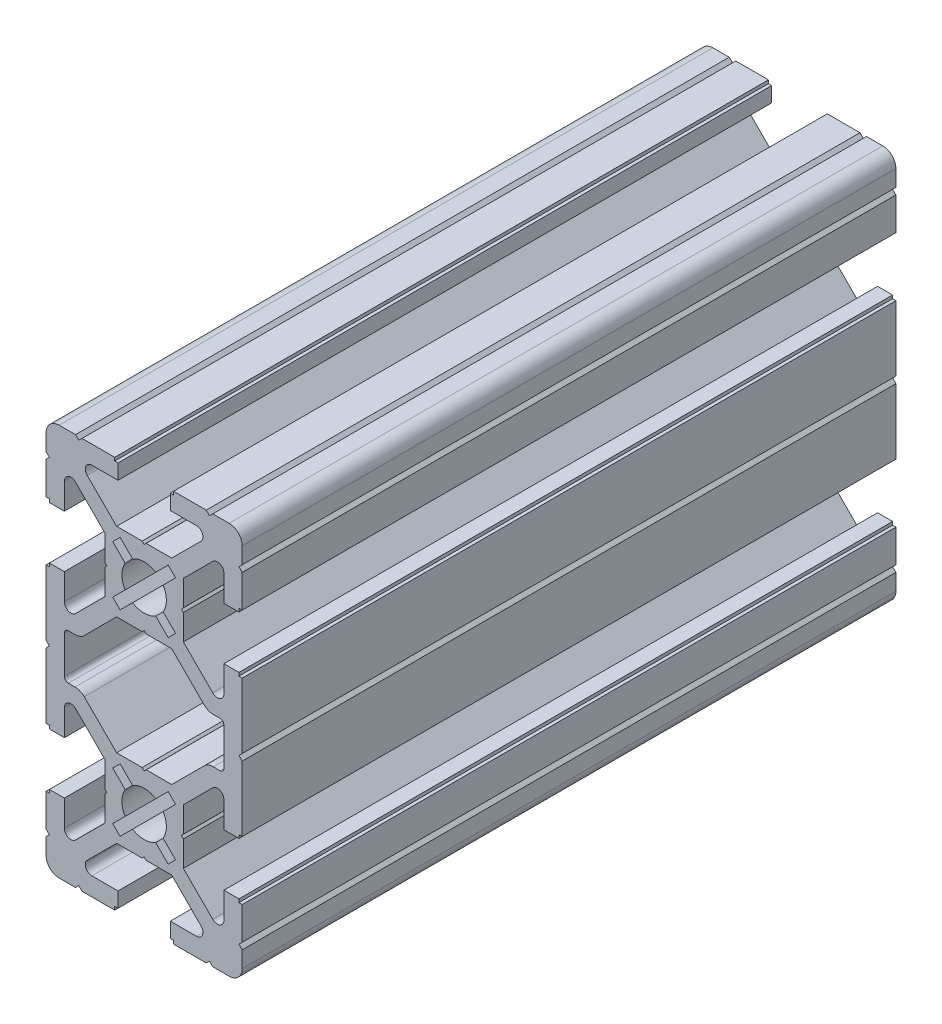
from build123d import *

# Parameters (mm, degrees)
Y_KSEKLIK_EKSTR_ZYON1_DEPTH = 100


with BuildPart() as part:
    # Çizim1 → Yükseklik-Ekstrüzyon1 (new body)
    with BuildSketch(Plane.XY.offset(100)):
        with BuildLine():
            Line((-4.214213564, 21), (-8.70710678, 25.492893215))
            ThreePointArc((-8.70710678, 25.492893215), (-8.923879532, 26.582683434), (-7.999999995, 27.200000005))
            Line((-7.999999995, 27.200000005), (-4.000000001, 27.200000005))
            Line((-4.000000001, 27.200000005), (-4.000000001, 29.500000001))
            Line((-4.000000001, 29.500000001), (-4.500000001, 29.500000001))
            Line((-4.500000001, 29.500000001), (-4.500000001, 29.999999999))
            Line((-4.500000001, 29.999999999), (-9.500000003, 29.999999999))
            Line((-9.500000003, 29.999999999), (-10.000000002, 29.499999999))
            Line((-10.000000002, 29.499999999), (-10.500000001, 29.999999999))
            Line((-10.500000001, 29.999999999), (-13, 29.999999999))
            ThreePointArc((-13, 29.999999999), (-14.414213562, 29.414213561), (-15, 27.999999999))
            Line((-15, 27.999999999), (-15, 25.5))
            Line((-15, 25.5), (-14.500000001, 25.000000001))
            Line((-14.500000001, 25.000000001), (-15, 24.500000001))
            Line((-15, 24.500000001), (-15, 19.5))
            Line((-15, 19.5), (-14.5, 19.5))
            Line((-14.5, 19.5), (-14.5, 19))
            Line((-14.5, 19), (-12.200000005, 19))
            Line((-12.200000005, 19), (-12.200000005, 22.999999994))
            ThreePointArc((-12.200000005, 22.999999994), (-11.582683434, 23.923879532), (-10.492893215, 23.707106779))
            Line((-10.492893215, 23.707106779), (-6, 19.214213564))
            Line((-6, 19.214213564), (-6, 15.312520901))
            Line((-6, 15.312520901), (-5.7, 15))
            Line((-5.7, 15), (-6, 14.687479097))
            Line((-6, 14.687479097), (-6, 10.785786436))
            Line((-6, 10.785786436), (-10.492893215, 6.29289322))
            ThreePointArc((-10.492893215, 6.29289322), (-11.582683434, 6.076120468), (-12.200000005, 7.000000005))
            Line((-12.200000005, 7.000000005), (-12.200000005, 11))
            Line((-12.200000005, 11), (-14.5, 11))
            Line((-14.5, 11), (-14.5, 10.5))
            Line((-14.5, 10.5), (-15, 10.5))
            Line((-15, 10.5), (-15, 0.499999999))
            Line((-15, 0.499999999), (-14.5, -1e-09))
            Line((-14.5, -1e-09), (-15, -0.500000001))
            Line((-15, -0.500000001), (-15, -10.5))
            Line((-15, -10.5), (-14.5, -10.5))
            Line((-14.5, -10.5), (-14.5, -11))
            Line((-14.5, -11), (-12.200000005, -11))
            Line((-12.200000005, -11), (-12.200000005, -7.000000006))
            ThreePointArc((-12.200000005, -7.000000006), (-11.582683434, -6.076120468), (-10.492893215, -6.292893221))
            Line((-10.492893215, -6.292893221), (-6, -10.785786436))
            Line((-6, -10.785786436), (-6, -14.687479097))
            Line((-6, -14.687479097), (-5.7, -15))
            Line((-5.7, -15), (-6, -15.312520901))
            Line((-6, -15.312520901), (-6, -19.214213564))
            Line((-6, -19.214213564), (-10.492893215, -23.70710678))
            ThreePointArc((-10.492893215, -23.70710678), (-11.582683434, -23.923879532), (-12.200000005, -22.999999995))
            Line((-12.200000005, -22.999999995), (-12.200000005, -19))
            Line((-12.200000005, -19), (-14.5, -19))
            Line((-14.5, -19), (-14.5, -19.5))
            Line((-14.5, -19.5), (-15, -19.5))
            Line((-15, -19.5), (-15, -24.500000001))
            Line((-15, -24.500000001), (-14.500000001, -25.000000001))
            Line((-14.500000001, -25.000000001), (-15, -25.5))
            Line((-15, -25.5), (-15, -27.999999999))
            ThreePointArc((-15, -27.999999999), (-14.414213562, -29.414213562), (-13, -29.999999999))
            Line((-13, -29.999999999), (-10.500000001, -29.999999999))
            Line((-10.500000001, -29.999999999), (-10.000000001, -29.5))
            Line((-10.000000001, -29.5), (-9.500000002, -29.999999999))
            Line((-9.500000002, -29.999999999), (-4.500000001, -29.999999999))
            Line((-4.500000001, -29.999999999), (-4.500000001, -29.499999999))
            Line((-4.500000001, -29.499999999), (-4.000000001, -29.499999999))
            Line((-4.000000001, -29.499999999), (-4.000000001, -27.200000005))
            Line((-4.000000001, -27.200000005), (-7.999999995, -27.200000005))
            ThreePointArc((-7.999999995, -27.200000005), (-8.923879532, -26.582683434), (-8.70710678, -25.492893215))
            Line((-8.70710678, -25.492893215), (-4.214213564, -21))
            Line((-4.214213564, -21), (-0.312520903, -21))
            Line((-0.312520903, -21), (0, -20.7))
            Line((0, -20.7), (0.312520901, -21))
            Line((0.312520901, -21), (4.214213564, -21))
            Line((4.214213564, -21), (8.70710678, -25.492893215))
            ThreePointArc((8.70710678, -25.492893215), (8.923879532, -26.582683434), (7.999999995, -27.200000005))
            Line((7.999999995, -27.200000005), (3.999999999, -27.200000005))
            Line((3.999999999, -27.200000005), (3.999999999, -29.499999999))
            Line((3.999999999, -29.499999999), (4.499999999, -29.499999999))
            Line((4.499999999, -29.499999999), (4.499999999, -29.999999999))
            Line((4.499999999, -29.999999999), (9.500000001, -29.999999999))
            Line((9.500000001, -29.999999999), (10, -29.5))
            Line((10, -29.5), (10.499999999, -29.999999999))
            Line((10.499999999, -29.999999999), (12.999999998, -29.999999999))
            ThreePointArc((12.999999998, -29.999999999), (14.41421356, -29.414213562), (14.999999998, -27.999999999))
            Line((14.999999998, -27.999999999), (14.999999998, -25.499999999))
            Line((14.999999998, -25.499999999), (14.499999999, -25.000000001))
            Line((14.499999999, -25.000000001), (14.999999998, -24.500000002))
            Line((14.999999998, -24.500000002), (14.999999998, -19.5))
            Line((14.999999998, -19.5), (14.5, -19.5))
            Line((14.5, -19.5), (14.5, -19))
            Line((14.5, -19), (12.200000005, -19))
            Line((12.200000005, -19), (12.200000005, -22.999999995))
            ThreePointArc((12.200000005, -22.999999995), (11.582683434, -23.923879532), (10.492893215, -23.70710678))
            Line((10.492893215, -23.70710678), (6, -19.214213564))
            Line((6, -19.214213564), (6, -15.312520903))
            Line((6, -15.312520903), (5.7, -15))
            Line((5.7, -15), (6, -14.687479099))
            Line((6, -14.687479099), (6, -10.785786436))
            Line((6, -10.785786436), (10.492893215, -6.29289322))
            ThreePointArc((10.492893215, -6.29289322), (11.582683434, -6.076120468), (12.200000005, -7.000000005))
            Line((12.200000005, -7.000000005), (12.200000005, -11))
            Line((12.200000005, -11), (14.5, -11))
            Line((14.5, -11), (14.5, -10.5))
            Line((14.5, -10.5), (14.999999998, -10.5))
            Line((14.999999998, -10.5), (14.999999998, -0.5))
            Line((14.999999998, -0.5), (14.499999998, 0))
            Line((14.499999998, 0), (14.999999998, 0.5))
            Line((14.999999998, 0.5), (14.999999998, 10.5))
            Line((14.999999998, 10.5), (14.5, 10.5))
            Line((14.5, 10.5), (14.5, 11))
            Line((14.5, 11), (12.200000005, 11))
            Line((12.200000005, 11), (12.200000005, 7.000000005))
            ThreePointArc((12.200000005, 7.000000005), (11.582683434, 6.076120468), (10.492893215, 6.292893221))
            Line((10.492893215, 6.292893221), (6, 10.785786436))
            Line((6, 10.785786436), (6, 14.687479099))
            Line((6, 14.687479099), (5.7, 15))
            Line((5.7, 15), (6, 15.312520903))
            Line((6, 15.312520903), (6, 19.214213564))
            Line((6, 19.214213564), (10.492893215, 23.70710678))
            ThreePointArc((10.492893215, 23.70710678), (11.582683434, 23.923879532), (12.200000005, 22.999999995))
            Line((12.200000005, 22.999999995), (12.200000005, 19))
            Line((12.200000005, 19), (14.5, 19))
            Line((14.5, 19), (14.5, 19.5))
            Line((14.5, 19.5), (14.999999998, 19.5))
            Line((14.999999998, 19.5), (14.999999998, 24.500000002))
            Line((14.999999998, 24.500000002), (14.499999999, 25.000000001))
            Line((14.499999999, 25.000000001), (14.999999998, 25.500000001))
            Line((14.999999998, 25.500000001), (14.999999998, 27.999999999))
            ThreePointArc((14.999999998, 27.999999999), (14.41421356, 29.414213561), (12.999999998, 29.999999999))
            Line((12.999999998, 29.999999999), (10.499999999, 29.999999999))
            Line((10.499999999, 29.999999999), (9.999999999, 29.499999999))
            Line((9.999999999, 29.499999999), (9.5, 29.999999999))
            Line((9.5, 29.999999999), (4.499999999, 29.999999999))
            Line((4.499999999, 29.999999999), (4.499999999, 29.500000001))
            Line((4.499999999, 29.500000001), (3.999999999, 29.500000001))
            Line((3.999999999, 29.500000001), (3.999999999, 27.200000005))
            Line((3.999999999, 27.200000005), (7.999999994, 27.200000005))
            ThreePointArc((7.999999994, 27.200000005), (8.923879532, 26.582683434), (8.707106779, 25.492893215))
            Line((8.707106779, 25.492893215), (4.214213564, 21))
            Line((4.214213564, 21), (0.312520901, 21))
            Line((0.312520901, 21), (0, 20.7))
            Line((0, 20.7), (-0.312520903, 21))
            Line((-0.312520903, 21), (-4.214213564, 21))
        make_face()
        with BuildLine():
            Line((-2.902349714, 16.770978864), (-4.808326112, 18.676955262))
            Line((-4.808326112, 18.676955262), (-3.676955262, 19.808326112))
            Line((-3.676955262, 19.808326112), (-1.770978864, 17.902349714))
            ThreePointArc((-1.770978864, 17.902349714), (0, 18.4), (1.770978864, 17.902349714))
            Line((1.770978864, 17.902349714), (3.676955262, 19.808326112))
            Line((3.676955262, 19.808326112), (4.808326112, 18.676955262))
            Line((4.808326112, 18.676955262), (2.902349714, 16.770978864))
            ThreePointArc((2.902349714, 16.770978864), (3.4, 15), (2.902349714, 13.229021136))
            Line((2.902349714, 13.229021136), (4.808326112, 11.323044738))
            Line((4.808326112, 11.323044738), (3.676955262, 10.191673888))
            Line((3.676955262, 10.191673888), (1.770978864, 12.097650286))
            ThreePointArc((1.770978864, 12.097650286), (0, 11.6), (-1.770978864, 12.097650286))
            Line((-1.770978864, 12.097650286), (-3.676955262, 10.191673888))
            Line((-3.676955262, 10.191673888), (-4.808326112, 11.323044738))
            Line((-4.808326112, 11.323044738), (-2.902349714, 13.229021136))
            ThreePointArc((-2.902349714, 13.229021136), (-3.4, 15), (-2.902349714, 16.770978864))
        make_face(mode=Mode.SUBTRACT)
        with BuildLine():
            Line((-2.902349714, -13.229021136), (-4.808326112, -11.323044738))
            Line((-4.808326112, -11.323044738), (-3.676955262, -10.191673888))
            Line((-3.676955262, -10.191673888), (-1.770978864, -12.097650286))
            ThreePointArc((-1.770978864, -12.097650286), (0, -11.6), (1.770978864, -12.097650286))
            Line((1.770978864, -12.097650286), (3.676955262, -10.191673888))
            Line((3.676955262, -10.191673888), (4.808326112, -11.323044738))
            Line((4.808326112, -11.323044738), (2.902349714, -13.229021136))
            ThreePointArc((2.902349714, -13.229021136), (3.4, -15), (2.902349714, -16.770978864))
            Line((2.902349714, -16.770978864), (4.808326112, -18.676955262))
            Line((4.808326112, -18.676955262), (3.676955262, -19.808326112))
            Line((3.676955262, -19.808326112), (1.770978864, -17.902349714))
            ThreePointArc((1.770978864, -17.902349714), (0, -18.4), (-1.770978864, -17.902349714))
            Line((-1.770978864, -17.902349714), (-3.676955262, -19.808326112))
            Line((-3.676955262, -19.808326112), (-4.808326112, -18.676955262))
            Line((-4.808326112, -18.676955262), (-2.902349714, -16.770978864))
            ThreePointArc((-2.902349714, -16.770978864), (-3.4, -15), (-2.902349714, -13.229021136))
        make_face(mode=Mode.SUBTRACT)
        with BuildLine():
            Line((-9.158427127, 4.055786438), (-4.214213564, 9))
            Line((-4.214213564, 9), (-0.312520901, 9))
            Line((-0.312520901, 9), (0, 9.3))
            Line((0, 9.3), (0.312520903, 9))
            Line((0.312520903, 9), (4.214213564, 9))
            Line((4.214213564, 9), (9.158427127, 4.055786438))
            ThreePointArc((9.158427127, 4.055786438), (9.807273824, 3.622240935), (10.572640689, 3.47))
            Line((10.572640689, 3.47), (11.600000005, 3.47))
            ThreePointArc((11.600000005, 3.47), (12.024264074, 3.294264069), (12.200000005, 2.87))
            Line((12.200000005, 2.87), (12.200000005, -2.87))
            ThreePointArc((12.200000005, -2.87), (12.024264074, -3.294264069), (11.600000005, -3.47))
            Line((11.600000005, -3.47), (10.572640689, -3.47))
            ThreePointArc((10.572640689, -3.47), (9.807273824, -3.622240935), (9.158427127, -4.055786438))
            Line((9.158427127, -4.055786438), (4.214213564, -9))
            Line((4.214213564, -9), (0.312520903, -9))
            Line((0.312520903, -9), (0, -9.3))
            Line((0, -9.3), (-0.312520901, -9))
            Line((-0.312520901, -9), (-4.214213564, -9))
            Line((-4.214213564, -9), (-9.158427127, -4.055786438))
            ThreePointArc((-9.158427127, -4.055786438), (-9.807273824, -3.622240935), (-10.572640689, -3.47))
            Line((-10.572640689, -3.47), (-11.600000005, -3.47))
            ThreePointArc((-11.600000005, -3.47), (-12.024264074, -3.294264069), (-12.200000005, -2.87))
            Line((-12.200000005, -2.87), (-12.200000005, 2.87))
            ThreePointArc((-12.200000005, 2.87), (-12.024264074, 3.294264069), (-11.600000005, 3.47))
            Line((-11.600000005, 3.47), (-10.572640689, 3.47))
            ThreePointArc((-10.572640689, 3.47), (-9.807273824, 3.622240935), (-9.158427127, 4.055786438))
        make_face(mode=Mode.SUBTRACT)
    extrude(amount=-Y_KSEKLIK_EKSTR_ZYON1_DEPTH)


solid = part.part
